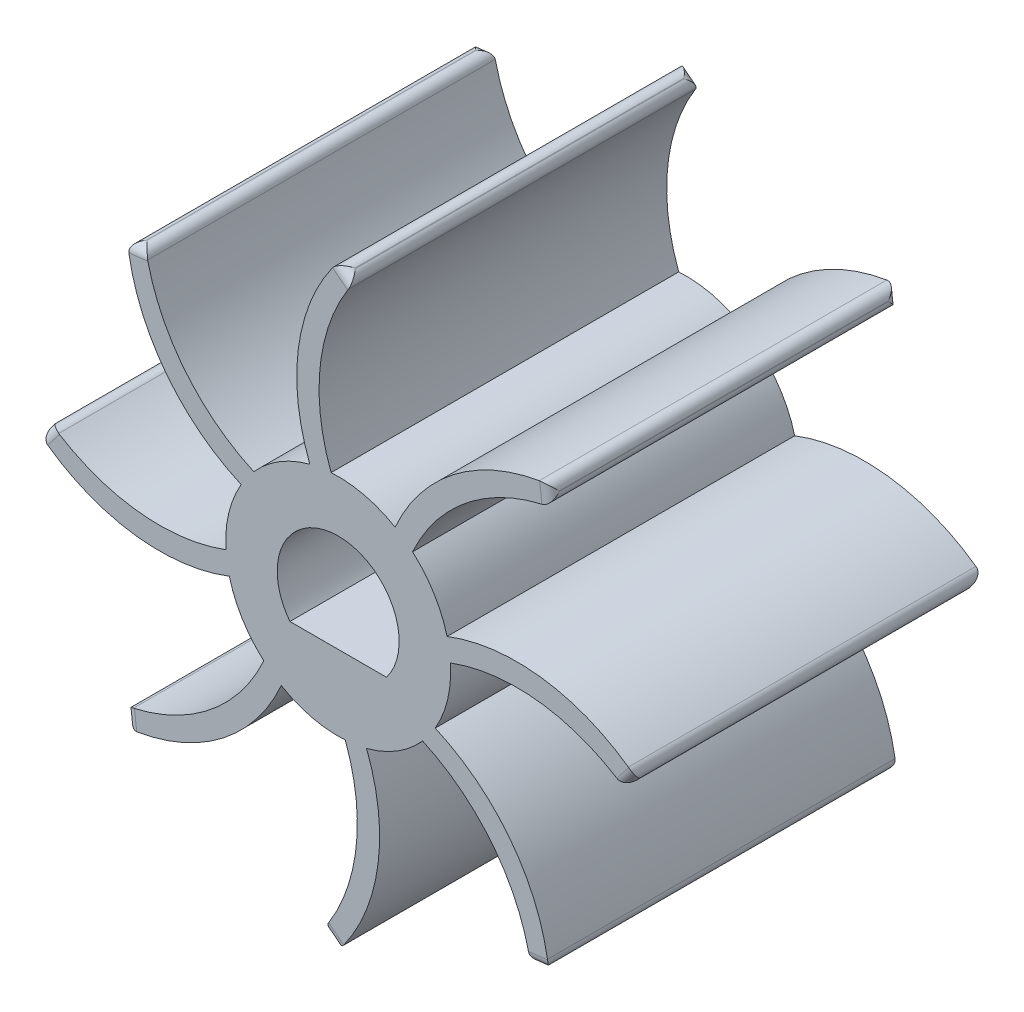
from build123d import *

# Parameters (mm, degrees)
SKETCH1_R           = 9.061638146
BOSS_EXTRUDE1_DEPTH = 28
FILLET1_R           = 0.75


with BuildPart() as part:
    # Sketch1 → Boss-Extrude1 (new body)
    with BuildSketch(Plane.XY):
        Circle(SKETCH1_R)
        with BuildLine():
            ThreePointArc((3.888321502, -3), (0, 4.911114344), (-3.888321502, -3))
            Line((-3.888321502, -3), (3.888321502, -3))
        make_face(mode=Mode.SUBTRACT)
        with BuildLine():
            ThreePointArc((-4.58615413, -7.815399938), (-5.312879632, -7.340749002), (-5.990857259, -6.798743648))
            ThreePointArc((-5.990857259, -6.798743648), (-10.498546947, -12.514092303), (-17.145581833, -15.480808299))
            Line((-17.145581833, -15.480808299), (-16.970562748, -16.970562748))
            ThreePointArc((-16.970562748, -16.970562748), (-9.561507432, -14.039044926), (-4.58615413, -7.815399938))
        make_face()
        with BuildLine():
            ThreePointArc((-8.769222979, -2.283421609), (-8.947466614, -1.433920183), (-9.04361353, -0.571261944))
            ThreePointArc((-9.04361353, -0.571261944), (-16.272393267, -1.425205789), (-23.070341708, 1.177172655))
            Line((-23.070341708, 1.177172655), (-24, 0))
            ThreePointArc((-24, 0), (-16.688110612, -3.166097125), (-8.769222979, -2.283421609))
        make_face()
        with BuildLine():
            ThreePointArc((-7.815399938, 4.58615413), (-7.340749002, 5.312879632), (-6.798743648, 5.990857259))
            ThreePointArc((-6.798743648, 5.990857259), (-12.514092303, 10.498546947), (-15.480808299, 17.145581833))
            Line((-15.480808299, 17.145581833), (-16.970562748, 16.970562748))
            ThreePointArc((-16.970562748, 16.970562748), (-14.039044926, 9.561507432), (-7.815399938, 4.58615413))
        make_face()
        with BuildLine():
            Line((1.177172655, 23.070341708), (0, 24))
            ThreePointArc((0, 24), (-3.166097125, 16.688110612), (-2.283421609, 8.769222979))
            ThreePointArc((-2.283421609, 8.769222979), (-1.433920183, 8.947466614), (-0.571261944, 9.04361353))
            ThreePointArc((-0.571261944, 9.04361353), (-1.425205789, 16.272393267), (1.177172655, 23.070341708))
        make_face()
        with BuildLine():
            ThreePointArc((16.970562748, 16.970562748), (9.561507432, 14.039044926), (4.58615413, 7.815399938))
            ThreePointArc((4.58615413, 7.815399938), (5.312879632, 7.340749002), (5.990857259, 6.798743648))
            ThreePointArc((5.990857259, 6.798743648), (10.498546947, 12.514092303), (17.145581833, 15.480808299))
            Line((17.145581833, 15.480808299), (16.970562748, 16.970562748))
        make_face()
        with BuildLine():
            ThreePointArc((24, 0), (16.688110612, 3.166097125), (8.769222979, 2.283421609))
            ThreePointArc((8.769222979, 2.283421609), (8.947466614, 1.433920183), (9.04361353, 0.571261944))
            ThreePointArc((9.04361353, 0.571261944), (16.272393267, 1.425205789), (23.070341708, -1.177172655))
            Line((23.070341708, -1.177172655), (24, 0))
        make_face()
        with BuildLine():
            ThreePointArc((16.970562748, -16.970562748), (14.039044926, -9.561507432), (7.815399938, -4.58615413))
            ThreePointArc((7.815399938, -4.58615413), (7.340749002, -5.312879632), (6.798743648, -5.990857259))
            ThreePointArc((6.798743648, -5.990857259), (12.514092303, -10.498546947), (15.480808299, -17.145581833))
            Line((15.480808299, -17.145581833), (16.970562748, -16.970562748))
        make_face()
        with BuildLine():
            ThreePointArc((2.283421609, -8.769222979), (1.433920183, -8.947466614), (0.571261944, -9.04361353))
            ThreePointArc((0.571261944, -9.04361353), (1.425205789, -16.272393267), (-1.177172655, -23.070341708))
            Line((-1.177172655, -23.070341708), (0, -24))
            ThreePointArc((0, -24), (3.166097125, -16.688110612), (2.283421609, -8.769222979))
        make_face()
    extrude(amount=BOSS_EXTRUDE1_DEPTH)

    # Fillet1
    fillet1_edges = [part.edges().sort_by_distance(p)[0] for p in [
        (-17.058072291, -16.225685524, 28),
        (-0.588586328, -23.535170854, 28),
        (16.225685524, -17.058072291, 28),
        (23.535170854, -0.588586328, 28),
        (16.225685524, -17.058072291, 0),
        (-0.588586328, -23.535170854, 0),
        (-17.058072291, -16.225685524, 0),
        (-23.535170854, 0.588586328, 0),
        (-16.225685524, 17.058072291, 0),
        (17.058072291, 16.225685524, 28),
        (0.588586328, 23.535170854, 0),
        (17.058072291, 16.225685524, 0),
        (23.535170854, -0.588586328, 0),
        (16.970562748, -16.970562748, 14),
        (15.480808299, -17.145581833, 14),
        (0, -24, 14),
        (-1.177172655, -23.070341708, 14),
        (0.588586328, 23.535170854, 28),
        (-16.970562748, -16.970562748, 14),
        (-17.145581833, -15.480808299, 14),
        (-24, 0, 14),
        (-23.070341708, 1.177172655, 14),
        (-16.970562748, 16.970562748, 14),
        (-15.480808299, 17.145581833, 14),
        (0, 24, 14),
        (1.177172655, 23.070341708, 14),
        (16.970562748, 16.970562748, 14),
        (17.145581833, 15.480808299, 14),
        (24, 0, 14),
        (23.070341708, -1.177172655, 14),
        (-16.225685524, 17.058072291, 28),
        (-23.535170854, 0.588586328, 28),
    ]]
    fillet(fillet1_edges, radius=FILLET1_R)


solid = part.part
